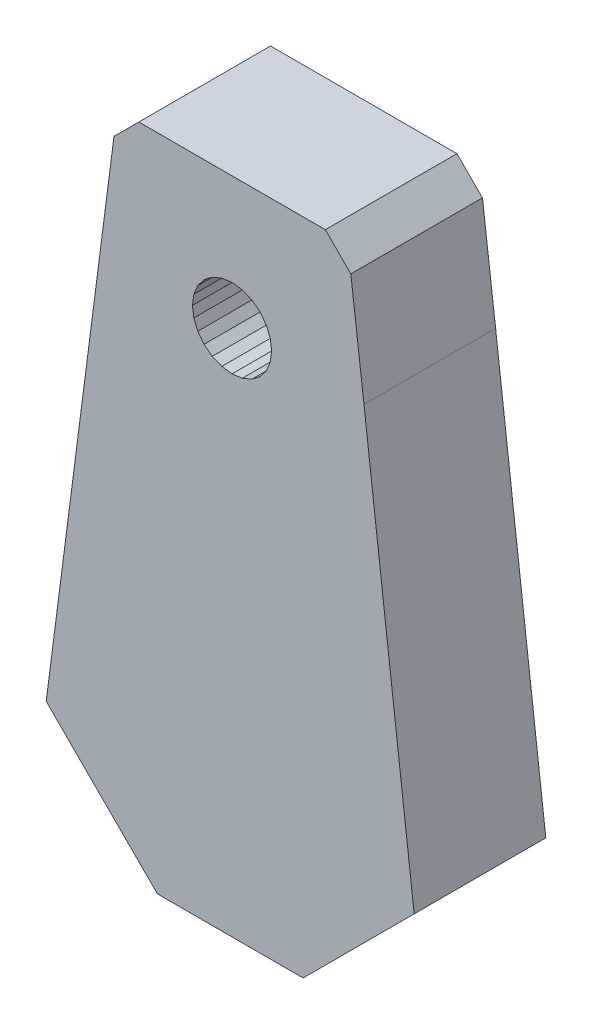
from build123d import *

# Parameters (mm, degrees)
BOSS_EXTRUDE1_DEPTH = 6


with BuildPart() as part:
    # Sketch1 → Boss-Extrude1 (new body)
    with BuildSketch(Plane.XY):
        Polygon((480.334233378, 258.110284779), (479.735399112, 262.960381303), (478.572022357, 264.123758058), (470.072022357, 264.123758058), (468.939958928, 262.991694629), (465.849271947, 239.145361455), (470.91743006, 234.077203343), (477.559378835, 234.077203343), (482.622244347, 239.140068855), align=None)
        Polygon((475.883106286, 259.012305771), (476.063330843, 258.577205203), (476.124802083, 258.110284779), (476.063330843, 257.643364355), (475.883106286, 257.208263787), (475.596410419, 256.834634459), (475.222781091, 256.547938592), (474.787680523, 256.367714035), (474.320760099, 256.306242795), (473.853839675, 256.367714035), (473.418739107, 256.547938592), (473.045109779, 256.834634459), (472.758413912, 257.208263787), (472.578189355, 257.643364355), (472.516718115, 258.110284779), (472.578189355, 258.577205203), (472.758413912, 259.012305771), (473.045109779, 259.385935099), (473.418739107, 259.672630966), (473.853839675, 259.852855523), (474.320760099, 259.914326763), (474.787680523, 259.852855523), (475.222781091, 259.672630966), (475.596410419, 259.385935099), align=None, mode=Mode.SUBTRACT)
    extrude(amount=BOSS_EXTRUDE1_DEPTH)


solid = part.part
